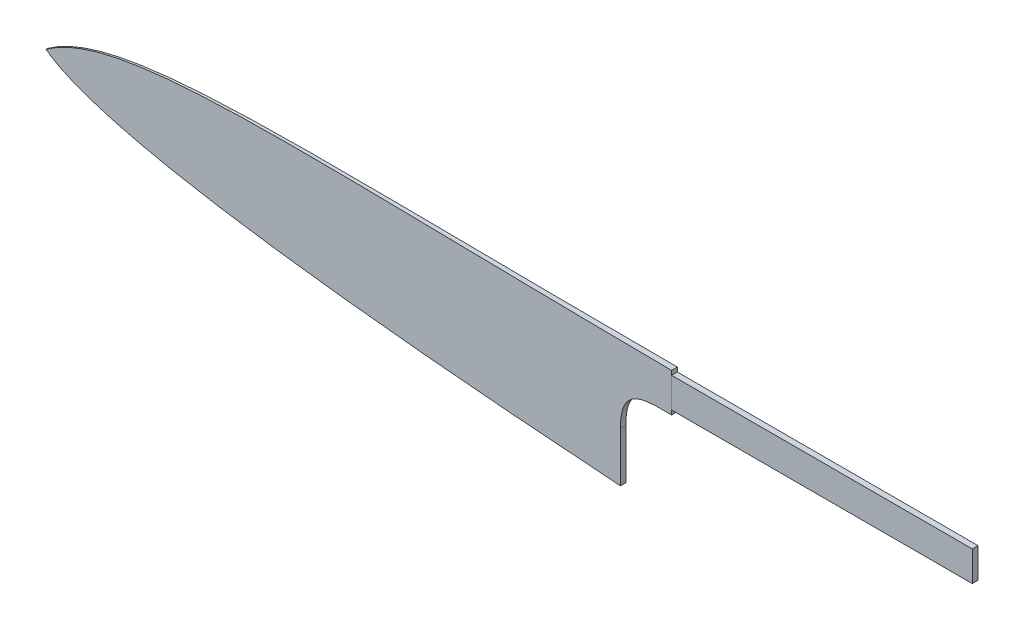
from build123d import *

# Parameters (mm, degrees)
BOSS_EXTRU_1_DEPTH      = 52
ESQUISSE4_W             = 351.485824357
ESQUISSE4_H             = 52
ENL_V_MAT_EXTRU_1_DEPTH = 52


with BuildPart() as part:
    # Esquisse3 → Boss.-Extru.1 (new body)
    with BuildSketch(Plane(origin=(0, 0, 0), x_dir=(1, 0, 0), z_dir=(0, 1, 0))):
        Polygon((341.486019825, 0), (0, 0), (-9.995686149, 0), (-9.999804532, -0.431819515), (0, -0.5), (220, -2), (341.486019825, -2), align=None)
    extrude(amount=BOSS_EXTRU_1_DEPTH)

    # Esquisse4 → Enlèv. mat.-Extru.1 (cut)
    with BuildSketch(Plane.XY.offset(2)):
        with Locations((165.743107647, 26)):
            Rectangle(ESQUISSE4_W, ESQUISSE4_H)
        with BuildLine():
            Line((325, 46.5), (325, 36))
            Line((325, 36), (220, 36))
            Line((220, 36), (220, 34.5))
            add(Edge.make_bspline(
                [(220, 34.5), (210.148627769, 34.5), (202, 34.902841403), (202, 21.363033151)],
                knots=[0, 0, 0, 0, 1, 1, 1, 1], degree=3))
            Line((202, 21.363033151), (202, 4))
            add(Edge.make_bspline(
                [(202, 4), (25.782341649, 14.763588637), (0, 34.373939813)],
                knots=[0, 0, 0, 1, 1, 1], degree=2))
            add(Edge.make_bspline(
                [(0, 34.373939813), (26.740576578, 53.810637401), (88.50602407, 48), (220, 48)],
                knots=[0, 0, 0, 0, 1, 1, 1, 1], degree=3))
            Line((220, 48), (220, 46.5))
            Line((220, 46.5), (325, 46.5))
        make_face(mode=Mode.SUBTRACT)
    extrude(amount=-ENL_V_MAT_EXTRU_1_DEPTH, mode=Mode.SUBTRACT)


solid = part.part
